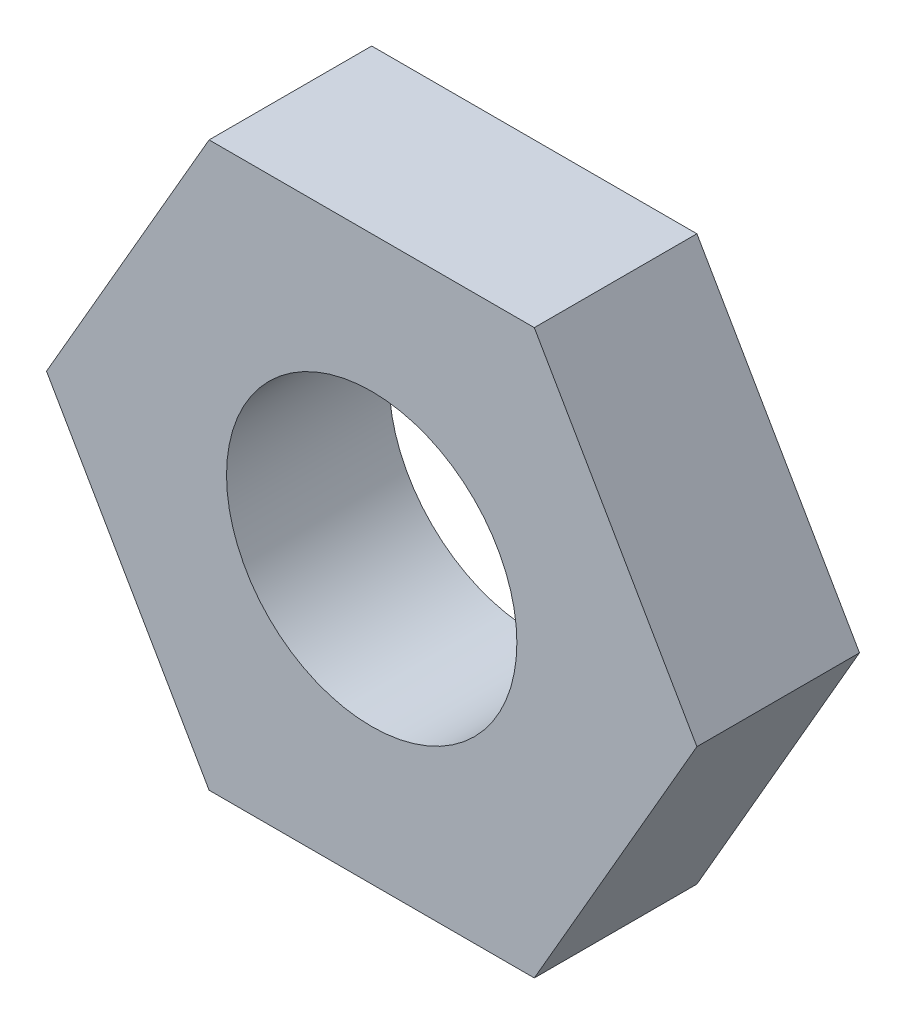
from build123d import *

# Parameters (mm, degrees)
SKETCH2_R           = 3.175
BOSS_EXTRUDE1_DEPTH = 3.556


with BuildPart() as part:
    # Sketch2 → Boss-Extrude1 (new body)
    with BuildSketch(Plane.XY):
        Polygon((-7.112, 0), (-3.556, -6.159172672), (3.556, -6.159172672), (7.112, 0), (3.556, 6.159172672), (-3.556, 6.159172672), align=None)
        Circle(SKETCH2_R, mode=Mode.SUBTRACT)
    extrude(amount=BOSS_EXTRUDE1_DEPTH)


solid = part.part
